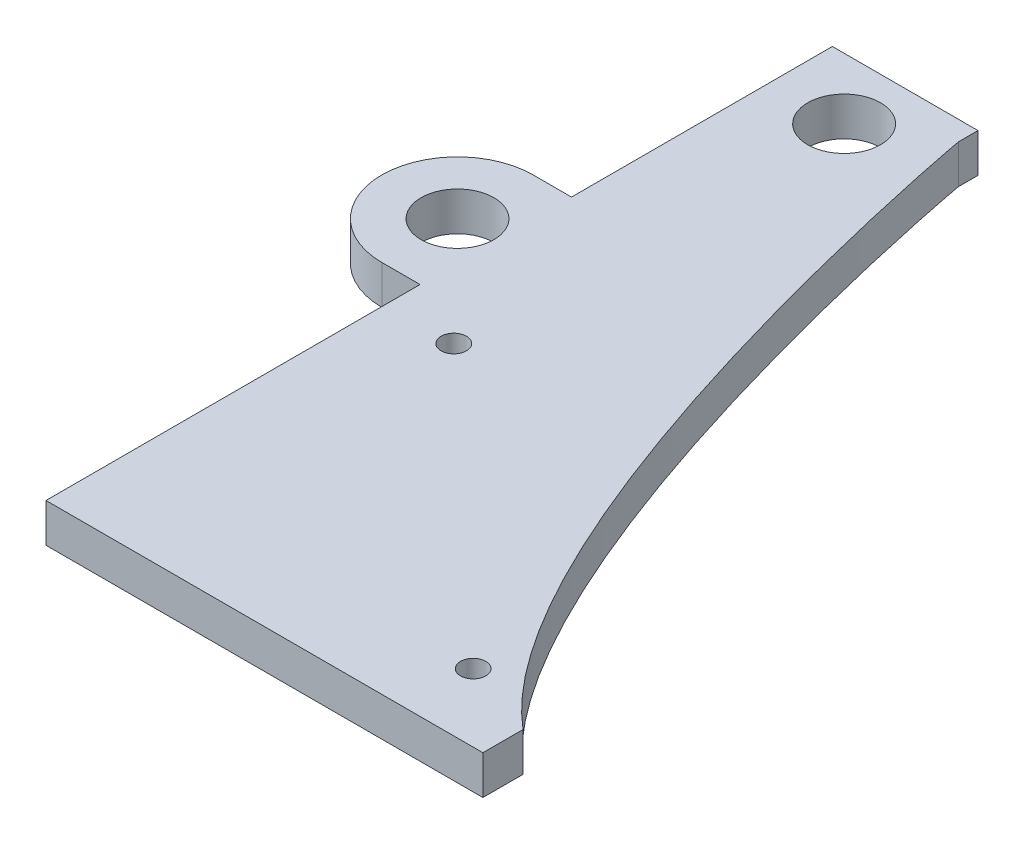
from build123d import *

# Parameters (mm, degrees)
SKETCH1_R               = 4.7625
BOSS_EXTRUDE1_DEPTH     = 5.08
SKETCH4_W               = 19.05
SKETCH4_H               = 5.08
BOSS_EXTRUDE2_DEPTH     = 5.08
SKETCH5_R               = 1.660728382
SKETCH5_R_2             = 1.651
CUT_EXTRUDE1_DEPTH      = 1.0000001
CUT_EXTRUDE1_DEPTH_BACK = 6.0800001
SKETCH6_R               = 4.7625
BOSS_EXTRUDE3_DEPTH     = 5.08
CUT_EXTRUDE2_DEPTH      = 1.0000001
CUT_EXTRUDE2_DEPTH_BACK = 6.0800001


with BuildPart() as part:
    # Sketch1 → Boss-Extrude1 (new body)
    with BuildSketch(Plane(origin=(0, 0, 0), x_dir=(1, 0, 0), z_dir=(0, 1, 0))):
        with BuildLine():
            Line((-9.525, 53.975), (9.525, 53.975))
            Line((9.525, 53.975), (9.525, 51.435))
            add(Edge.make_bspline(
                [(9.525, 51.435), (9.525, 51.21454564), (27.819109584, -48.895), (60.325, -48.895)],
                knots=[0, 0, 0, 0, 1, 1, 1, 1], degree=3))
            Line((60.325, -48.895), (-9.525, -48.895))
            Line((-9.525, -48.895), (-9.525, 53.975))
        make_face()
        with Locations((0, 45.9867)):
            Circle(SKETCH1_R, mode=Mode.SUBTRACT)
    extrude(amount=BOSS_EXTRUDE1_DEPTH)

    # Sketch4 → Boss-Extrude2 (add)
    with BuildSketch(Plane(origin=(0, 5.08, 0), x_dir=(1, 0, 0), z_dir=(0, 1, 0))):
        with Locations((50.8, -51.435)):
            Rectangle(SKETCH4_W, SKETCH4_H)
    extrude(amount=-BOSS_EXTRUDE2_DEPTH)

    # Sketch5 → Cut-Extrude1 (cut, two sides)
    with BuildSketch(Plane.XZ) as cut_extrude1_sk:
        with Locations((-0.635, 4.445)):
            Circle(SKETCH5_R)
        with Locations((37.465, 40.005)):
            Circle(SKETCH5_R_2)
    extrude(amount=CUT_EXTRUDE1_DEPTH, mode=Mode.SUBTRACT)
    extrude(cut_extrude1_sk.sketch, amount=-CUT_EXTRUDE1_DEPTH_BACK, mode=Mode.SUBTRACT)

    # Sketch6 → Boss-Extrude3 (add)
    with BuildSketch(Plane.XZ):
        with BuildLine():
            Line((-14.535912, -0.037592), (-9.525, -0.037592))
            Line((-9.525, -0.037592), (-9.525, -1.398441508))
            ThreePointArc((-9.525, -1.398441508), (-4.629912, -9.943592), (-9.525, -18.488742492))
            Line((-9.525, -18.488742492), (-9.525, -19.849592))
            Line((-9.525, -19.849592), (-14.535912, -19.849592))
            ThreePointArc((-14.535912, -19.849592), (-24.441912, -9.943592), (-14.535912, -0.037592))
        make_face()
        with Locations((-14.535912, -9.943592)):
            Circle(SKETCH6_R, mode=Mode.SUBTRACT)
    extrude(amount=-BOSS_EXTRUDE3_DEPTH)

    # Sketch9 → Cut-Extrude2 (cut, two sides)
    with BuildSketch(Plane.XZ) as cut_extrude2_sk:
        with BuildLine():
            Line((60.325, 53.975), (60.325, 48.895))
            add(Edge.make_bspline(
                [(60.325, 48.895), (55.814379896, 48.895), (51.577410685, 46.967369191), (47.625, 43.646486826)],
                knots=[0, 0, 0, 0, 0.138763161, 0.138763161, 0.138763161, 0.138763161], degree=3))
            Line((47.625, 43.646486826), (47.625, 48.895))
            Line((47.625, 48.895), (41.275, 48.895))
            Line((41.275, 48.895), (41.275, 53.975))
            Line((41.275, 53.975), (60.325, 53.975))
        make_face()
    extrude(amount=CUT_EXTRUDE2_DEPTH, mode=Mode.SUBTRACT)
    extrude(cut_extrude2_sk.sketch, amount=-CUT_EXTRUDE2_DEPTH_BACK, mode=Mode.SUBTRACT)


solid = part.part
